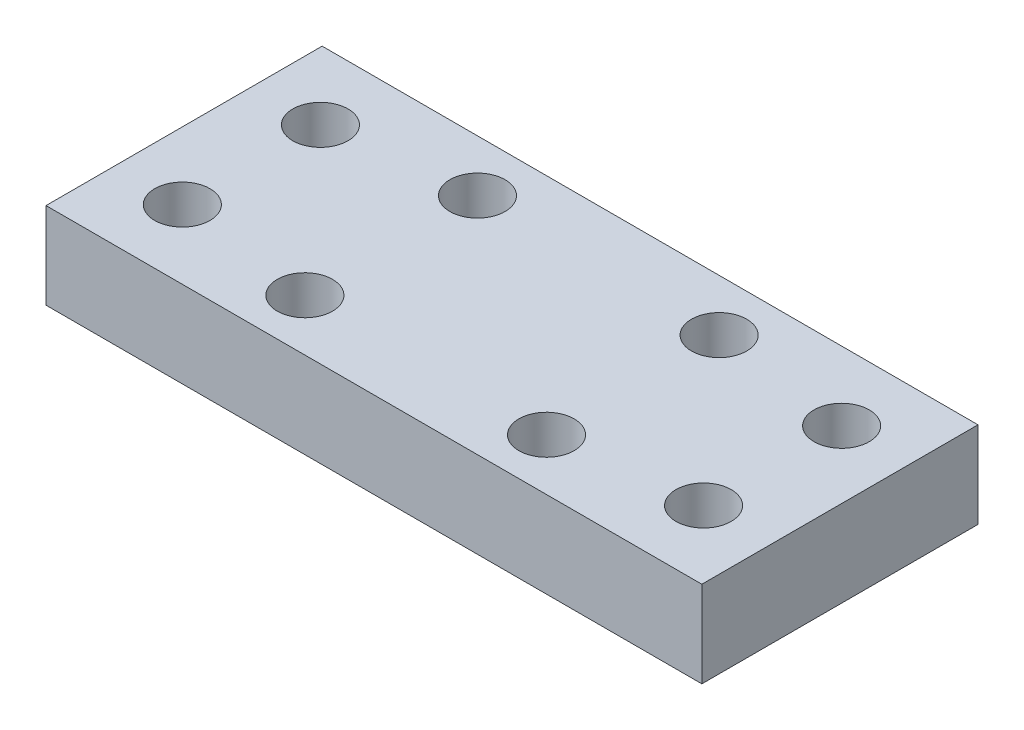
from build123d import *

# Parameters (mm, degrees)
SKETCH1_R           = 1.6
BOSS_EXTRUDE1_DEPTH = 5


with BuildPart() as part:
    # Sketch1 → Boss-Extrude1 (new body)
    with BuildSketch(Plane(origin=(0, 0, 0), x_dir=(1, 0, 0), z_dir=(0, 1, 0))):
        Polygon((-19, 4), (19, 4), (19, -12), (-19, -12), (-19, -4), align=None)
        with Locations((-7, 1)):
            Circle(SKETCH1_R, mode=Mode.SUBTRACT)
        with Locations((7, 1)):
            Circle(SKETCH1_R, mode=Mode.SUBTRACT)
        with Locations((15.1, 0)):
            Circle(SKETCH1_R, mode=Mode.SUBTRACT)
        with Locations((-15.1, 0)):
            Circle(SKETCH1_R, mode=Mode.SUBTRACT)
        with Locations((-15.1, -8)):
            Circle(SKETCH1_R, mode=Mode.SUBTRACT)
        with Locations((15.1, -8)):
            Circle(SKETCH1_R, mode=Mode.SUBTRACT)
        with Locations((7, -9)):
            Circle(SKETCH1_R, mode=Mode.SUBTRACT)
        with Locations((-7, -9)):
            Circle(SKETCH1_R, mode=Mode.SUBTRACT)
    extrude(amount=BOSS_EXTRUDE1_DEPTH)


solid = part.part
